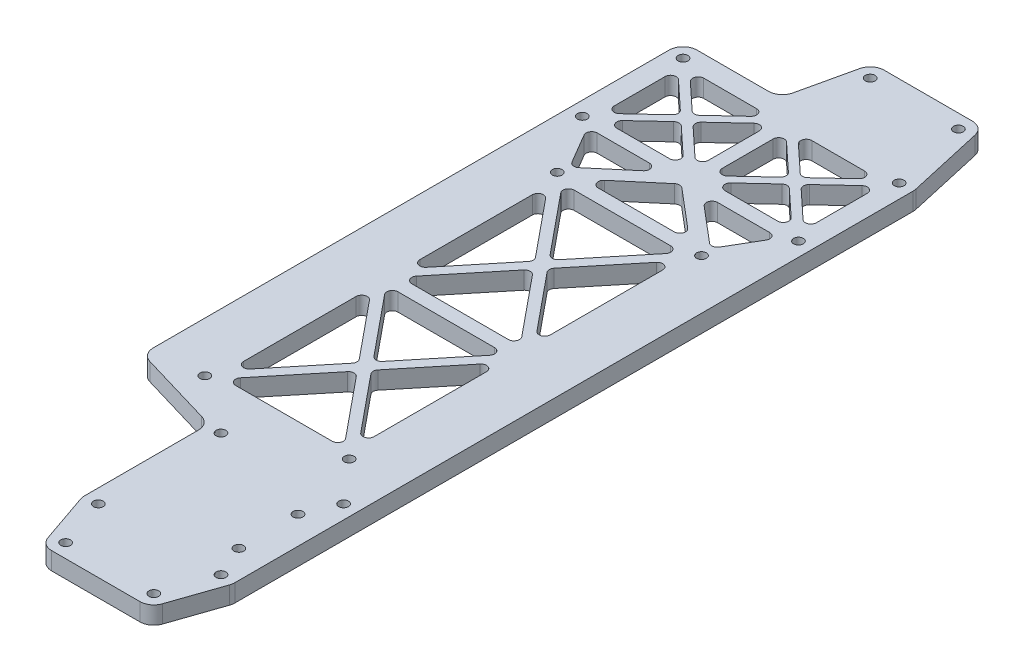
from build123d import *

# Parameters (mm, degrees)
SKETCH1_R           = 1.75
BOSS_EXTRUDE1_DEPTH = 6.35
FILLET1_R           = 5.05
CUT_EXTRUDE1_DEPTH  = 10
FILLET2_R           = 2


with BuildPart() as part:
    # Sketch1 → Boss-Extrude1 (new body)
    with BuildSketch(Plane(origin=(0, 0, 0), x_dir=(1, 0, 0), z_dir=(0, 1, 0))):
        with BuildLine():
            ThreePointArc((40.272577166, 3.371665468), (42.096697799, 0.929270787), (45, 0))
            Line((45, 0), (76.8, 0))
            ThreePointArc((76.8, 0), (79.703302201, 0.929270787), (81.527422834, 3.371665468))
            Line((81.527422834, 3.371665468), (87.727422834, 21.371665468))
            ThreePointArc((87.727422834, 21.371665468), (87.931384905, 22.174504443), (88, 23))
            Line((88, 23), (88, 267.5))
            ThreePointArc((88, 267.5), (87.968979977, 268.058873856), (87.876300995, 268.610881859))
            Line((87.876300995, 268.610881859), (81.677525738, 296.099883029))
            ThreePointArc((81.677525738, 296.099883029), (79.922545825, 298.905087396), (76.8, 300))
            Line((76.8, 300), (45, 300))
            ThreePointArc((45, 300), (41.877454175, 298.905087396), (40.122474262, 296.099883029))
            Line((40.122474262, 296.099883029), (34.811970933, 272.55))
            Line((34.811970933, 272.55), (0, 272.55))
            Line((0, 272.55), (0, 77.816418218))
            Line((0, 77.816418218), (33.8, 67.816418218))
            Line((33.8, 67.816418218), (33.8, 23))
            ThreePointArc((33.8, 23), (33.868615095, 22.174504443), (34.072577166, 21.371665468))
            Line((34.072577166, 21.371665468), (40.272577166, 3.371665468))
        make_face()
        with Locations((38.8, 23)):
            Circle(SKETCH1_R, mode=Mode.SUBTRACT)
        with Locations((38.8, 67.2)):
            Circle(SKETCH1_R, mode=Mode.SUBTRACT)
        with Locations((18, 82.2)):
            Circle(SKETCH1_R, mode=Mode.SUBTRACT)
        with Locations((45, 5)):
            Circle(SKETCH1_R, mode=Mode.SUBTRACT)
        with Locations((76.8, 5)):
            Circle(SKETCH1_R, mode=Mode.SUBTRACT)
        with Locations((78, 34.45)):
            Circle(SKETCH1_R, mode=Mode.SUBTRACT)
        with Locations((83, 23)):
            Circle(SKETCH1_R, mode=Mode.SUBTRACT)
        with Locations((78, 55.75)):
            Circle(SKETCH1_R, mode=Mode.SUBTRACT)
        with Locations((83, 67.2)):
            Circle(SKETCH1_R, mode=Mode.SUBTRACT)
        with Locations((70, 82.2)):
            Circle(SKETCH1_R, mode=Mode.SUBTRACT)
        with Locations((18, 209.2)):
            Circle(SKETCH1_R, mode=Mode.SUBTRACT)
        with Locations((5.05, 231.2)):
            Circle(SKETCH1_R, mode=Mode.SUBTRACT)
        with Locations((5.05, 267.5)):
            Circle(SKETCH1_R, mode=Mode.SUBTRACT)
        with Locations((70, 209.2)):
            Circle(SKETCH1_R, mode=Mode.SUBTRACT)
        with Locations((45, 295)):
            Circle(SKETCH1_R, mode=Mode.SUBTRACT)
        with Locations((82.95, 231.2)):
            Circle(SKETCH1_R, mode=Mode.SUBTRACT)
        with Locations((76.8, 295)):
            Circle(SKETCH1_R, mode=Mode.SUBTRACT)
        with Locations((82.95, 267.5)):
            Circle(SKETCH1_R, mode=Mode.SUBTRACT)
    extrude(amount=BOSS_EXTRUDE1_DEPTH)

    # Fillet1
    fillet1_edges = [part.edges().sort_by_distance(p)[0] for p in [
        (33.8, 3.175, -67.816418218),
        (0, 3.175, -77.816418218),
        (0, 3.175, -272.55),
        (34.811970933, 3.175, -272.55),
    ]]
    fillet(fillet1_edges, radius=FILLET1_R)

    # Sketch2 → Cut-Extrude1 (cut)
    with BuildSketch(Plane(origin=(0, 6.35, 0), x_dir=(1, 0, 0), z_dir=(0, 1, 0))):
        Polygon((7.55, 235.58033772), (7.55, 263.11966228), (22.324885559, 249.35), align=None)
        Polygon((24.525, 251.400427579), (39.117378672, 265), (9.932621328, 265), align=None)
        Polygon((9.932621328, 233.7), (39.117378672, 233.7), (24.525, 247.299572421), align=None)
        Polygon((26.725114441, 249.35), (41.5, 235.58033772), (41.5, 263.11966228), align=None)
        Polygon((46.5, 235.58033772), (61.274885559, 249.35), (46.5, 263.11966228), align=None)
        Polygon((63.475, 251.400427579), (78.067378672, 265), (48.882621328, 265), align=None)
        Polygon((65.675114441, 249.35), (80.45, 235.58033772), (80.45, 263.11966228), align=None)
        Polygon((48.882621328, 233.7), (78.067378672, 233.7), (63.475, 247.299572421), align=None)
        Polygon((65.626230078, 206.7), (22.373769922, 206.7), (44, 180.291045962), align=None)
        Polygon((46.326525827, 177.45), (67.5, 151.593930578), (67.5, 203.306069422), align=None)
        Polygon((20.5, 151.593930578), (41.673474173, 177.45), (20.5, 203.306069422), align=None)
        Polygon((65.626230078, 148.2), (44, 174.608954038), (22.373769922, 148.2), align=None)
        Polygon((44, 116.791045962), (65.626230078, 143.2), (22.373769922, 143.2), align=None)
        Polygon((41.673474173, 113.95), (20.5, 139.806069422), (20.5, 88.093930578), align=None)
        Polygon((44, 111.108954038), (22.373769922, 84.7), (65.626230078, 84.7), align=None)
        Polygon((67.5, 139.806069422), (67.5, 88.093930578), (46.326525827, 113.95), align=None)
        Polygon((9.422552785, 228.7), (18.649664402, 213.024598025), (37.175139462, 228.7), align=None)
        Polygon((24.824860538, 211.7), (63.175139462, 211.7), (44, 227.925118007), align=None)
        Polygon((78.577447215, 228.7), (50.824860538, 228.7), (69.350335598, 213.024598025), align=None)
    extrude(amount=-CUT_EXTRUDE1_DEPTH, mode=Mode.SUBTRACT)

    # Fillet2
    fillet2_edges = [part.edges().sort_by_distance(p)[0] for p in [
        (65.626230078, 3.175, -143.2),
        (44, 3.175, -116.791045962),
        (22.373769922, 3.175, -143.2),
        (44, 3.175, -174.608954038),
        (65.626230078, 3.175, -148.2),
        (22.373769922, 3.175, -148.2),
        (41.673474173, 3.175, -177.45),
        (20.5, 3.175, -151.593930578),
        (20.5, 3.175, -203.306069422),
        (67.5, 3.175, -151.593930578),
        (46.326525827, 3.175, -177.45),
        (67.5, 3.175, -203.306069422),
        (9.422552785, 3.175, -228.7),
        (37.175139462, 3.175, -228.7),
        (18.649664402, 3.175, -213.024598025),
        (67.5, 3.175, -139.806069422),
        (67.5, 3.175, -88.093930578),
        (46.326525827, 3.175, -113.95),
        (20.5, 3.175, -139.806069422),
        (41.673474173, 3.175, -113.95),
        (20.5, 3.175, -88.093930578),
        (22.373769922, 3.175, -84.7),
        (44, 3.175, -111.108954038),
        (65.626230078, 3.175, -84.7),
        (61.274885559, 3.175, -249.35),
        (46.5, 3.175, -235.58033772),
        (46.5, 3.175, -263.11966228),
        (41.5, 3.175, -235.58033772),
        (26.725114441, 3.175, -249.35),
        (41.5, 3.175, -263.11966228),
        (39.117378672, 3.175, -233.7),
        (9.932621328, 3.175, -233.7),
        (24.525, 3.175, -247.299572421),
        (39.117378672, 3.175, -265),
        (24.525, 3.175, -251.400427579),
        (9.932621328, 3.175, -265),
        (22.373769922, 3.175, -206.7),
        (65.626230078, 3.175, -206.7),
        (44, 3.175, -180.291045962),
        (78.067378672, 3.175, -233.7),
        (48.882621328, 3.175, -233.7),
        (63.475, 3.175, -247.299572421),
        (78.067378672, 3.175, -265),
        (63.475, 3.175, -251.400427579),
        (48.882621328, 3.175, -265),
        (80.45, 3.175, -235.58033772),
        (65.675114441, 3.175, -249.35),
        (80.45, 3.175, -263.11966228),
        (78.577447215, 3.175, -228.7),
        (69.350335598, 3.175, -213.024598025),
        (50.824860538, 3.175, -228.7),
        (24.824860538, 3.175, -211.7),
        (44, 3.175, -227.925118007),
        (63.175139462, 3.175, -211.7),
        (7.55, 3.175, -235.58033772),
        (7.55, 3.175, -263.11966228),
        (22.324885559, 3.175, -249.35),
    ]]
    fillet(fillet2_edges, radius=FILLET2_R)


solid = part.part
